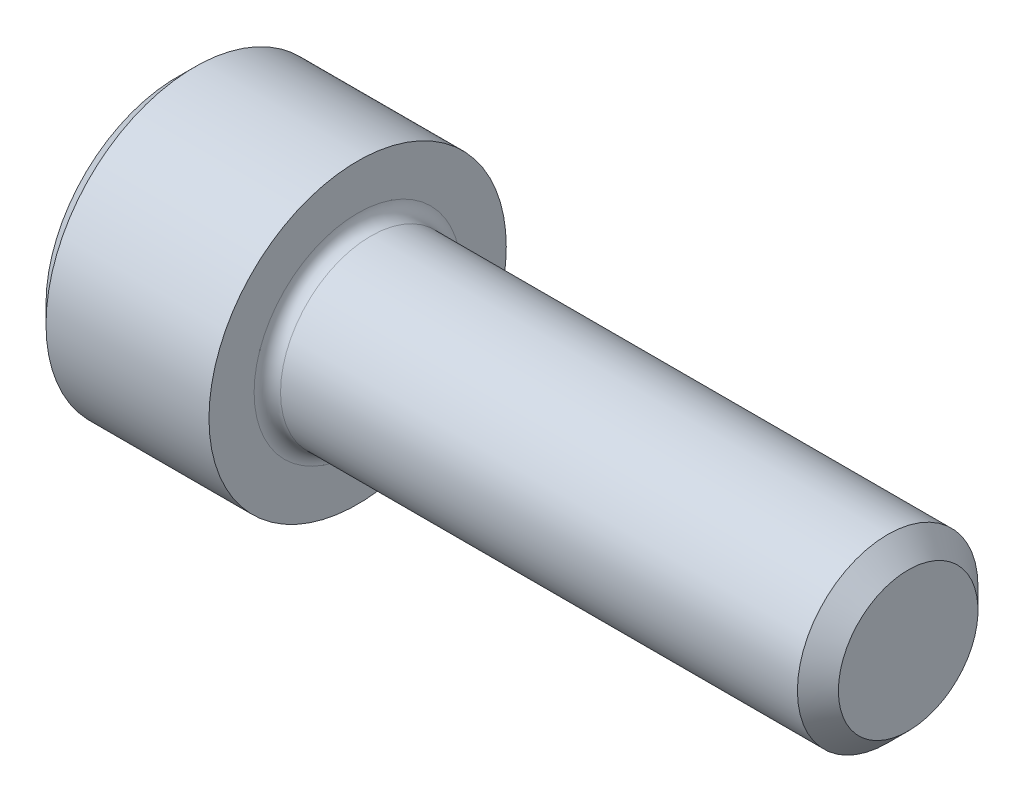
from build123d import *

# Parameters (mm, degrees)
FILLET1_R   = 0.3048
HEX_2_DEPTH = 1.9558


with BuildPart() as part:
    # BodySke → Base-Revolve (revolve)
    with BuildSketch(Plane.XY):
        Polygon((0, 0), (0, 3.0226), (0.4064, 3.429), (4.1656, 3.429), (4.1656, 2.0828), (16.39316, 2.0828), (16.8656, 1.61036), (16.8656, 0), align=None)
    revolve(axis=Axis((-31.75, 0, 0), (1, 0, 0)))

    # Fillet1
    fillet1_edges = [part.edges().sort_by_distance(p)[0] for p in [
        (4.1656, -2.0828, 0),
    ]]
    fillet(fillet1_edges, radius=FILLET1_R)

    # Sketch2 → Hex-PreBroach (revolve, cut)
    with BuildSketch(Plane.XY):
        Polygon((0, 1.778), (1.9558, 1.778), (2.982328779, 0), (0, 0), align=None)
    revolve(axis=Axis((0, 0, 0), (1, 0, 0)), mode=Mode.SUBTRACT)

    # Sketch3 → Hex 2 (cut)
    with BuildSketch(Plane(origin=(0, 0, 0), x_dir=(0, 0.5, 0.866025404), z_dir=(-1, 0, 0))):
        Polygon((1.026528779, 1.778), (-1.026528779, 1.778), (-2.053057557, 0), (-1.026528779, -1.778), (1.026528779, -1.778), (2.053057557, 0), align=None)
    extrude(amount=-HEX_2_DEPTH, mode=Mode.SUBTRACT)


solid = part.part
